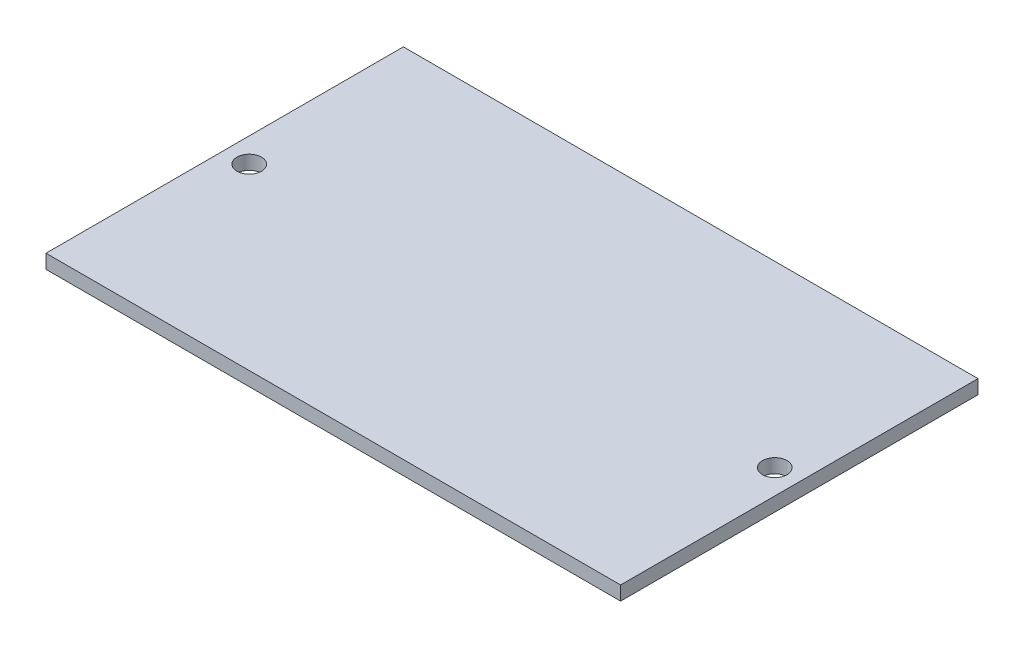
from build123d import *

# Parameters (mm, degrees)
SKETCH1_W           = 82
SKETCH1_H           = 51
BOSS_EXTRUDE1_DEPTH = 2
SKETCH2_R           = 1.75
CUT_EXTRUDE1_DEPTH  = 2


with BuildPart() as part:
    # Sketch1 → Boss-Extrude1 (new body)
    with BuildSketch(Plane(origin=(0, 0, 0), x_dir=(1, 0, 0), z_dir=(0, 1, 0))):
        with Locations((41, 25.5)):
            Rectangle(SKETCH1_W, SKETCH1_H)
    extrude(amount=BOSS_EXTRUDE1_DEPTH)

    # Sketch2 → Cut-Extrude1 (cut)
    with BuildSketch(Plane(origin=(0, 2, 0), x_dir=(1, 0, 0), z_dir=(0, 1, 0))):
        with Locations((3.5, 25.5)):
            Circle(SKETCH2_R)
        with Locations((78.5, 25.5)):
            Circle(SKETCH2_R)
    extrude(amount=-CUT_EXTRUDE1_DEPTH, mode=Mode.SUBTRACT)


solid = part.part
